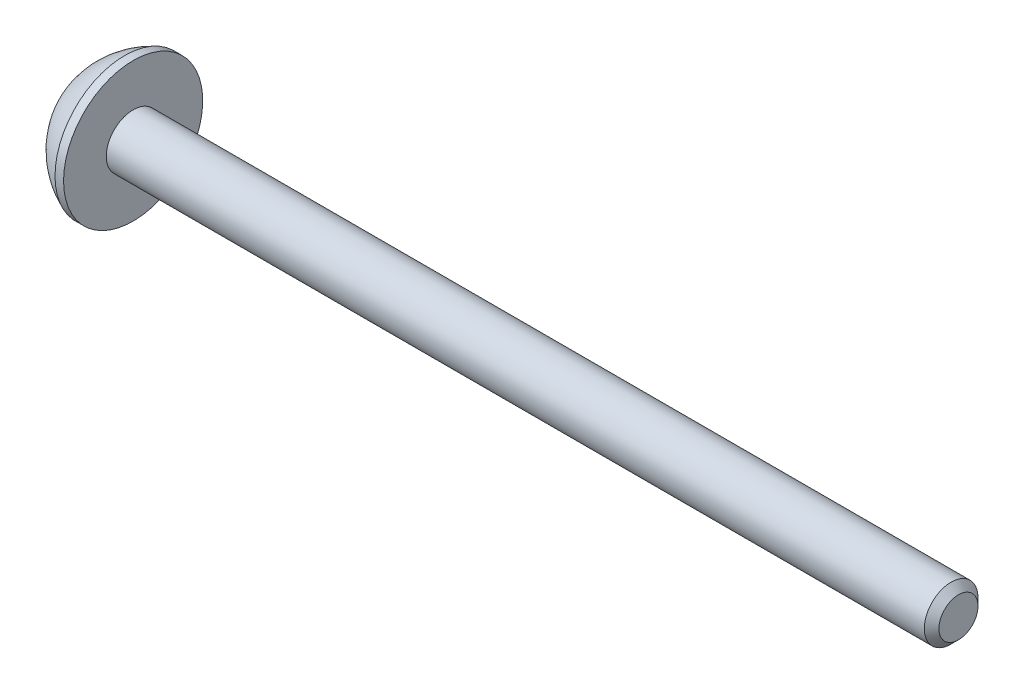
from build123d import *

# Parameters (mm, degrees)
SKETCH1_W          = 33.5
SKETCH1_H          = 1.1
CUT_EXTRUDE1_DEPTH = 1
SCALE1_SCALE       = 2


with BuildPart() as part:
    # Sketch1 → Revolve1 (revolve)
    with BuildSketch(Plane.XY):
        with Locations((4.269842451, 0.55)):
            Rectangle(SKETCH1_W, SKETCH1_H)
        with BuildLine():
            Line((-12.830157549, 0), (-12.830157549, 2.85))
            ThreePointArc((-12.830157549, 2.85), (-13.77738043, 2.26408121), (-14.480157549, 1.4))
            Line((-14.480157549, 1.4), (-14.480157549, 0))
            Line((-14.480157549, 0), (-12.830157549, 0))
        make_face()
        Polygon((-12.480157549, 1.1), (-12.480157549, 2.85), (-12.830157549, 2.85), (-12.830157549, 0), (-12.480157549, 0), align=None)
        Polygon((21.319842451, 0.8), (21.019842451, 1.1), (21.019842451, 0), (21.319842451, 0), align=None)
    revolve(axis=Axis((-12.480157549, 0, 0), (1, 0, 0)))

    # Sketch2 → Cut-Extrude1 (cut)
    with BuildSketch(Plane.ZY.offset(14.480157549)):
        Polygon((0, 1.154700538), (-1, 0.577350269), (-1, -0.577350269), (0, -1.154700538), (1, -0.577350269), (1, 0.577350269), align=None)
    extrude(amount=-CUT_EXTRUDE1_DEPTH, mode=Mode.SUBTRACT)


with BuildPart() as part_1:
    # Scale1: scaled about (0.733669991, 0, 0)
    add(part.part.scale(SCALE1_SCALE).moved(Location((-0.733669991, 0, 0))))


solid = part_1.part
